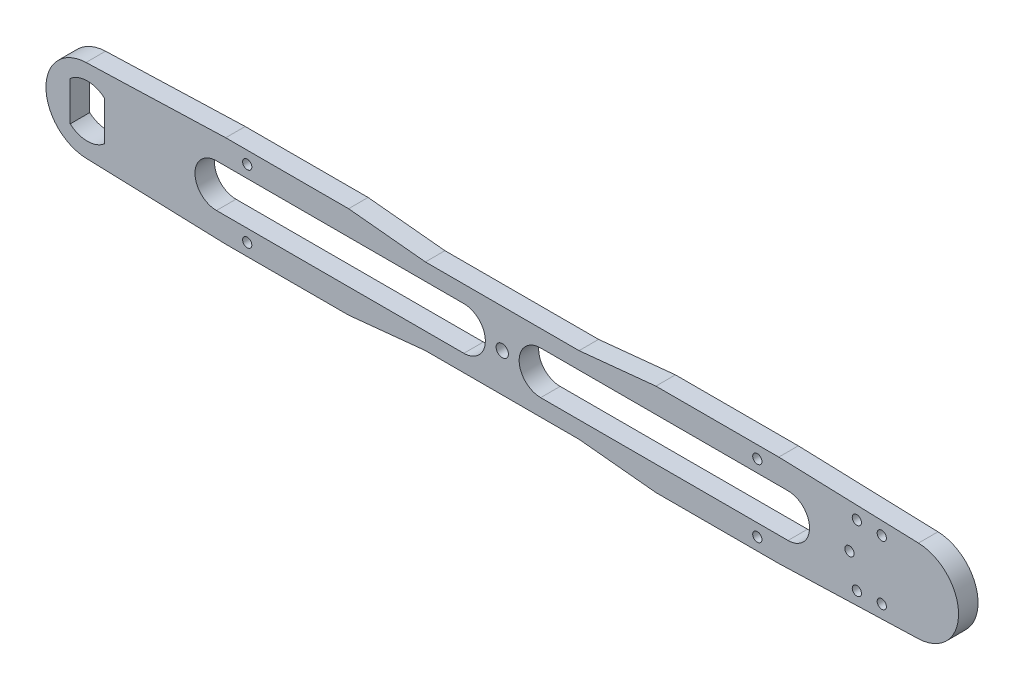
from build123d import *

# Parameters (mm, degrees)
CROQUIS1_R              = 13.5
SALIENTE_EXTRUIR1_DEPTH = 6.35
CORTAR_EXTRUIR1_DEPTH   = 6.35
CORTAR_EXTRUIR3_DEPTH   = 10
CROQUIS4_R              = 1.5
CROQUIS4_R_2            = 2
CORTAR_EXTRUIR4_DEPTH   = 10
CROQUIS5_R              = 1.5
CORTAR_EXTRUIR5_DEPTH   = 7.35
CROQUIS6_R              = 1.5
CORTAR_EXTRUIR6_DEPTH   = 7.35


with BuildPart() as part:
    # Croquis1 → Saliente-Extruir1 (new body)
    with BuildSketch(Plane.XY):
        Circle(CROQUIS1_R)
        with BuildLine():
            Line((85, 15), (45, 15))
            Line((45, 15), (-0.447526726, 13.492580177))
            ThreePointArc((-0.447526726, 13.492580177), (9.386383468, 9.702876141), (13.5, 0))
            ThreePointArc((13.5, 0), (9.386383468, -9.702876141), (-0.447526726, -13.492580177))
            Line((-0.447526726, -13.492580177), (45, -15))
            Line((45, -15), (85, -15))
            Line((85, -15), (110, -12.5))
            Line((110, -12.5), (160, -12.5))
            Line((160, -12.5), (185, -15))
            Line((185, -15), (225, -15))
            Line((225, -15), (270.447526726, -13.492580177))
            ThreePointArc((270.447526726, -13.492580177), (256.5, 0), (270.447526726, 13.492580177))
            Line((270.447526726, 13.492580177), (225, 15))
            Line((225, 15), (185, 15))
            Line((185, 15), (160, 12.5))
            Line((160, 12.5), (110, 12.5))
            Line((110, 12.5), (85, 15))
        make_face()
        with Locations((270, 0)):
            Circle(CROQUIS1_R)
    extrude(amount=SALIENTE_EXTRUIR1_DEPTH)

    # Croquis2 → Cortar-Extruir1 (cut)
    with BuildSketch(Plane.XY.offset(6.35)):
        with BuildLine():
            ThreePointArc((5.6, 6.394528911), (0, 8.5), (-5.6, 6.394528911))
            Line((-5.6, 6.394528911), (-5.6, -6.394528911))
            ThreePointArc((-5.6, -6.394528911), (0, -8.5), (5.6, -6.394528911))
            Line((5.6, -6.394528911), (5.6, 6.394528911))
        make_face()
    extrude(amount=-CORTAR_EXTRUIR1_DEPTH, mode=Mode.SUBTRACT)

    # Croquis3 → Cortar-Extruir3 (cut)
    with BuildSketch(Plane.XY.offset(6.35)):
        with BuildLine():
            Line((122.5, 7), (42, 7))
            ThreePointArc((42, 7), (35, 0), (42, -7))
            Line((42, -7), (122.5, -7))
            ThreePointArc((122.5, -7), (129.5, 0), (122.5, 7))
        make_face()
        with BuildLine():
            Line((228, 7), (147.5, 7))
            ThreePointArc((147.5, 7), (140.5, 0), (147.5, -7))
            Line((147.5, -7), (228, -7))
            ThreePointArc((228, -7), (235, 0), (228, 7))
        make_face()
    extrude(amount=-CORTAR_EXTRUIR3_DEPTH, mode=Mode.SUBTRACT)

    # Croquis4 → Cortar-Extruir4 (cut)
    with BuildSketch(Plane.XY.offset(6.35)):
        with Locations((52, 11)):
            Circle(CROQUIS4_R)
        with Locations((52, -11)):
            Circle(CROQUIS4_R)
        with Locations((218, -11)):
            Circle(CROQUIS4_R)
        with Locations((218, 11)):
            Circle(CROQUIS4_R)
        with Locations((135, 0)):
            Circle(CROQUIS4_R_2)
    extrude(amount=-CORTAR_EXTRUIR4_DEPTH, mode=Mode.SUBTRACT)

    # Croquis5 → Cortar-Extruir5 (cut, through all)
    with BuildSketch(Plane.XY.offset(6.35)):
        with Locations((248, 0)):
            Circle(CROQUIS5_R)
    extrude(amount=-CORTAR_EXTRUIR5_DEPTH, mode=Mode.SUBTRACT)

    # Croquis6 → Cortar-Extruir6 (cut, through all)
    with BuildSketch(Plane.XY.offset(6.35)):
        with Locations((250.397856468, 9.987790994)):
            Circle(CROQUIS6_R)
        with Locations((258.509333353, 9.641814145)):
            Circle(CROQUIS6_R)
        with Locations((258.509333353, -9.641814145)):
            Circle(CROQUIS6_R)
        with Locations((250.397856468, -9.987790994)):
            Circle(CROQUIS6_R)
    extrude(amount=-CORTAR_EXTRUIR6_DEPTH, mode=Mode.SUBTRACT)


solid = part.part
